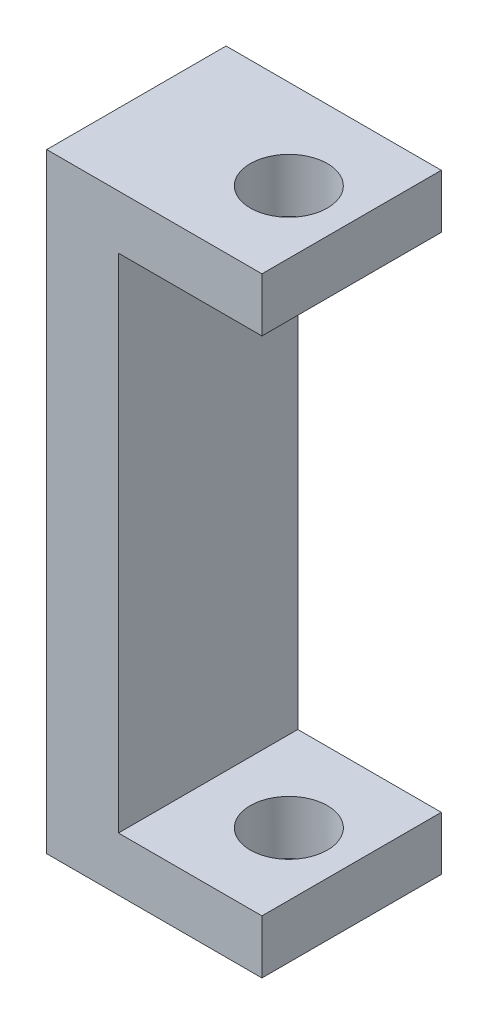
from build123d import *

# Parameters (mm, degrees)
SKETCH1_W               = 12
SKETCH1_H               = 34
BOSS_EXTRUDE1_DEPTH     = 5
SKETCH2_W               = 16
SKETCH2_H               = 28
CUT_EXTRUDE1_DEPTH      = 1
CUT_EXTRUDE1_DEPTH_BACK = 11
SKETCH3_R               = 2.15
CUT_EXTRUDE2_DEPTH      = 35


with BuildPart() as part:
    # Sketch1 → Boss-Extrude1 (new body, symmetric)
    with BuildSketch(Plane.XY):
        Rectangle(SKETCH1_W, SKETCH1_H)
    extrude(amount=BOSS_EXTRUDE1_DEPTH, both=True)

    # Sketch2 → Cut-Extrude1 (cut, two sides)
    with BuildSketch(Plane.XY.offset(5)) as cut_extrude1_sk:
        with Locations((6, 0)):
            Rectangle(SKETCH2_W, SKETCH2_H)
    extrude(amount=CUT_EXTRUDE1_DEPTH, mode=Mode.SUBTRACT)
    extrude(cut_extrude1_sk.sketch, amount=-CUT_EXTRUDE1_DEPTH_BACK, mode=Mode.SUBTRACT)

    # Sketch3 → Cut-Extrude2 (cut, through all)
    with BuildSketch(Plane(origin=(0, 17, 0), x_dir=(1, 0, 0), z_dir=(0, 1, 0))):
        with Locations((2.5, 0)):
            Circle(SKETCH3_R)
    extrude(amount=-CUT_EXTRUDE2_DEPTH, mode=Mode.SUBTRACT)


solid = part.part
